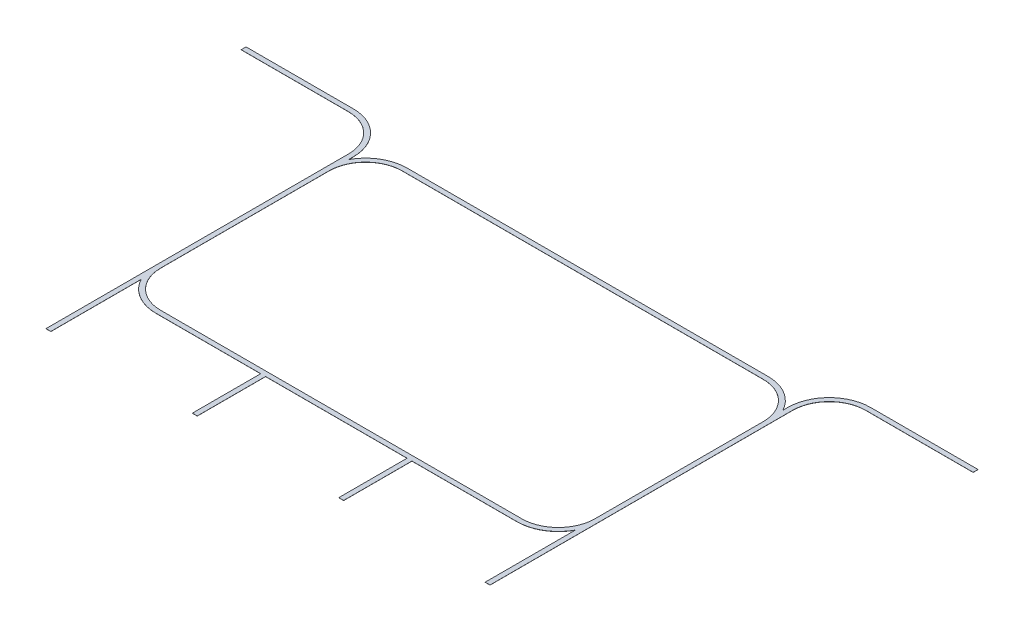
from build123d import *

# Parameters (mm, degrees)
EXTRUSION1_DEPTH = 0.5


with BuildPart() as part:
    # Esquisse1 → Extrusion1 (new body)
    with BuildSketch(Plane(origin=(0, 0, 0), x_dir=(1, 0, 0), z_dir=(0, 1, 0))):
        with BuildLine():
            Line((-740, 20), (740, 20))
            ThreePointArc((740, 20), (827.464278423, -4.226202629), (890, -70))
            Line((890, -70), (890, -50))
            ThreePointArc((890, -50), (939.791847198, 70.208152802), (1060, 120))
            Line((1060, 120), (1500, 120))
            Line((1500, 120), (1500, 100))
            Line((1500, 100), (1060, 100))
            ThreePointArc((1060, 100), (953.933982822, 56.066017178), (910, -50))
            Line((910, -50), (910, -1290))
            Line((910, -1290), (890, -1290))
            Line((890, -1290), (890, -920))
            ThreePointArc((890, -920), (827.464278423, -985.773797371), (740, -1010))
            Line((740, -1010), (310, -1010))
            Line((310, -1010), (310, -1290))
            Line((310, -1290), (290, -1290))
            Line((290, -1290), (290, -1010))
            Line((290, -1010), (-290, -1010))
            Line((-290, -1010), (-290, -1290))
            Line((-290, -1290), (-310, -1290))
            Line((-310, -1290), (-310, -1010))
            Line((-310, -1010), (-740, -1010))
            ThreePointArc((-740, -1010), (-827.464278423, -985.773797371), (-890, -920))
            Line((-890, -920), (-890, -1290))
            Line((-890, -1290), (-910, -1290))
            Line((-910, -1290), (-910, -50))
            ThreePointArc((-910, -50), (-953.933982822, 56.066017178), (-1060, 100))
            Line((-1060, 100), (-1500, 100))
            Line((-1500, 100), (-1500, 120))
            Line((-1500, 120), (-1060, 120))
            ThreePointArc((-1060, 120), (-939.791847198, 70.208152802), (-890, -50))
            Line((-890, -50), (-890, -70))
            ThreePointArc((-890, -70), (-827.464278423, -4.226202629), (-740, 20))
        make_face()
        with BuildLine():
            Line((-740, 0), (740, 0))
            ThreePointArc((740, 0), (846.066017178, -43.933982822), (890, -150))
            Line((890, -150), (890, -840))
            ThreePointArc((890, -840), (846.066017178, -946.066017178), (740, -990))
            Line((740, -990), (-740, -990))
            ThreePointArc((-740, -990), (-846.066017178, -946.066017178), (-890, -840))
            Line((-890, -840), (-890, -150))
            ThreePointArc((-890, -150), (-846.066017178, -43.933982822), (-740, 0))
        make_face(mode=Mode.SUBTRACT)
    extrude(amount=EXTRUSION1_DEPTH)


solid = part.part
